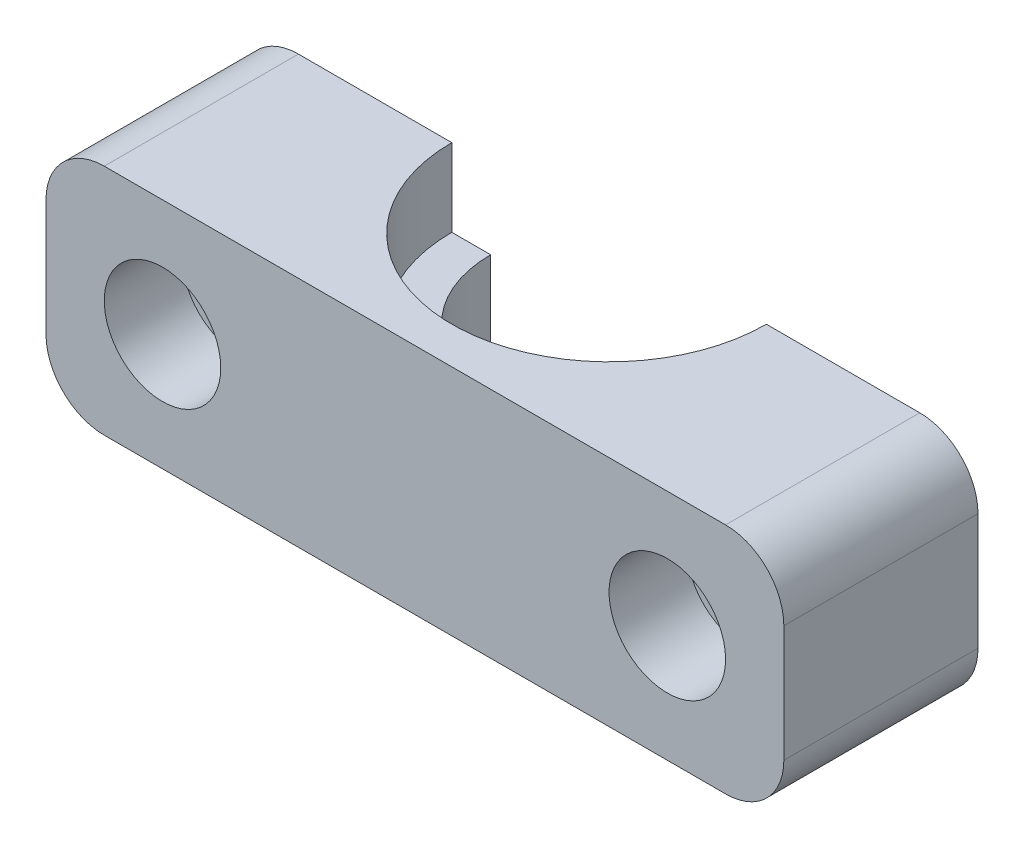
from build123d import *

# Parameters (mm, degrees)
ESBO_O1_W                = 38
ESBO_O1_H                = 12
ESBO_O1_R                = 1.7
RESSALTO_EXTRUS_O1_DEPTH = 10
FILETE1_R                = 3
ESBO_O2_R                = 8.1
CORTE_EXTRUS_O1_DEPTH    = 4
ESBO_O3_R                = 6.1
CORTE_EXTRUS_O2_DEPTH    = 5
CORTE_EXTRUS_O3_START    = -9
ESBO_O2_2_R              = 8.1
CORTE_EXTRUS_O3_DEPTH    = 4
ESBO_O4_R                = 3
CORTE_EXTRUS_O4_DEPTH    = 4


with BuildPart() as part:
    # Esboço1 → Ressalto-extrusão1 (new body)
    with BuildSketch(Plane.XY):
        Rectangle(ESBO_O1_W, ESBO_O1_H)
        with Locations((13, 0)):
            Circle(ESBO_O1_R, mode=Mode.SUBTRACT)
        with Locations((-13, 0)):
            Circle(ESBO_O1_R, mode=Mode.SUBTRACT)
    extrude(amount=RESSALTO_EXTRUS_O1_DEPTH)

    # Filete1
    filete1_edges = [part.edges().sort_by_distance(p)[0] for p in [
        (-19, -6, 5),
        (-19, 6, 5),
        (19, 6, 5),
        (19, -6, 5),
    ]]
    fillet(filete1_edges, radius=FILETE1_R)

    # Esboço2 → Corte-extrusão1 (cut)
    with BuildSketch(Plane(origin=(0, 6, 0), x_dir=(1, 0, 0), z_dir=(0, 1, 0))):
        Circle(ESBO_O2_R)
    extrude(amount=-CORTE_EXTRUS_O1_DEPTH, mode=Mode.SUBTRACT)

    # Esboço3 → Corte-extrusão2 (cut)
    with BuildSketch(Plane(origin=(0, 2, 0), x_dir=(1, 0, 0), z_dir=(0, 1, 0))):
        Circle(ESBO_O3_R)
    extrude(amount=-CORTE_EXTRUS_O2_DEPTH, mode=Mode.SUBTRACT)

    # Esboço2<2> → Corte-extrusão3 (cut)
    with BuildSketch(Plane(origin=(0, 6, 0), x_dir=(1, 0, 0), z_dir=(0, 1, 0)).offset(CORTE_EXTRUS_O3_START)):
        Circle(ESBO_O2_2_R)
    extrude(amount=-CORTE_EXTRUS_O3_DEPTH, mode=Mode.SUBTRACT)

    # Esboço4 → Corte-extrusão4 (cut)
    with BuildSketch(Plane.XY.offset(10)):
        with Locations((-13, 0)):
            Circle(ESBO_O4_R)
        with Locations((13, 0)):
            Circle(ESBO_O4_R)
    extrude(amount=-CORTE_EXTRUS_O4_DEPTH, mode=Mode.SUBTRACT)


solid = part.part
